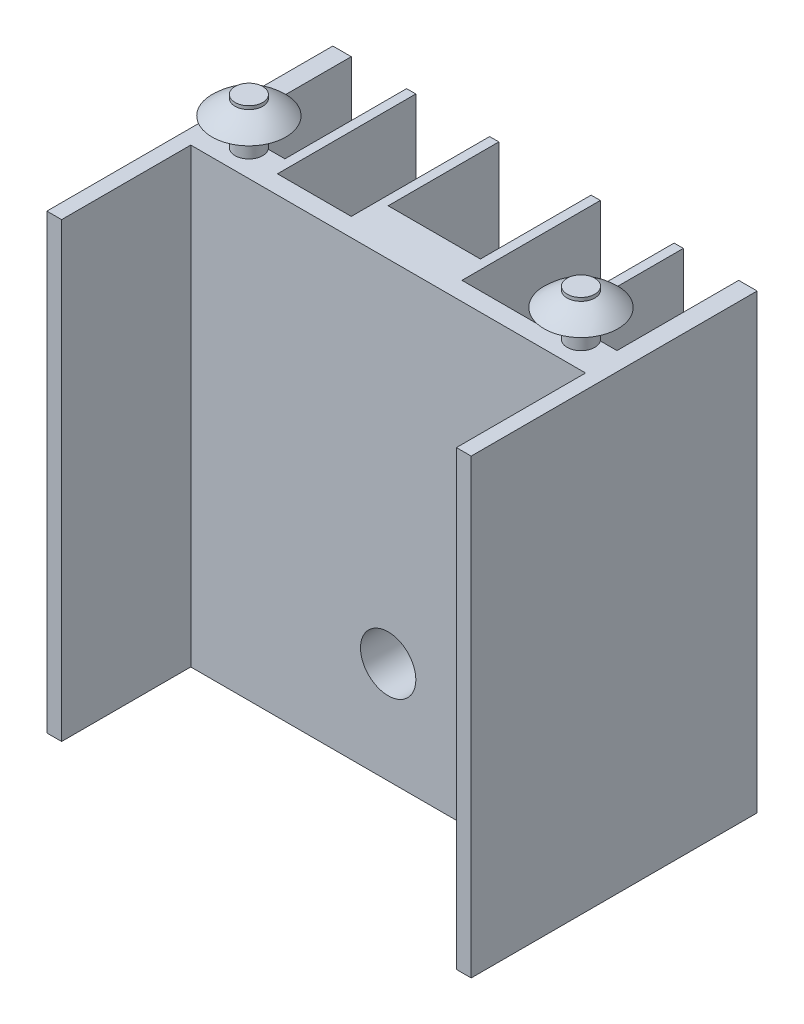
from build123d import *

# Parameters (mm, degrees)
IZIM1_W                          = 23
IZIM1_H                          = 15.5
Y_KSEKLIK_EKSTR_ZYON1_DEPTH      = 24.5
IZIM2_W                          = 21.4
IZIM2_H                          = 7
IZIM2_W_2                        = 5
IZIM2_H_2                        = 6
IZIM2_W_3                        = 4
IZIM2_H_3                        = 7.5
KES_EKSTR_ZYON1_DEPTH            = 24.5
IZIM3_R                          = 0.75
Y_KSEKLIK_EKSTR_ZYON4_DEPTH      = 2.5
Y_KSEKLIK_EKSTR_ZYON4_DEPTH_BACK = 10
IZIM8_R                          = 1.5
KES_EKSTR_ZYON3_DEPTH            = 10


with BuildPart() as part:
    # Çizim1 → Yükseklik-Ekstrüzyon1 (new body)
    with BuildSketch(Plane(origin=(0, 0, 0), x_dir=(1, 0, 0), z_dir=(0, 1, 0))):
        Rectangle(IZIM1_W, IZIM1_H)
    extrude(amount=Y_KSEKLIK_EKSTR_ZYON1_DEPTH)

    # Çizim2 → Kes-Ekstrüzyon1 (cut)
    with BuildSketch(Plane(origin=(0, 0, 0), x_dir=(1, 0, 0), z_dir=(0, 1, 0))):
        with Locations((0, -4.25)):
            Rectangle(IZIM2_W, IZIM2_H)
        Polygon((-8.5, 1.153663729), (-7.5, 1.153663729), (-7.5, 7.75), (-10.5, 7.75), (-10.5, 1.153663729), (-9.5, 1.153663729), (-9.5, 0.25), (-8.5, 0.25), align=None)
        with Locations((0, 4.75)):
            Rectangle(IZIM2_W_2, IZIM2_H_2)
        with Locations((-5, 4)):
            Rectangle(IZIM2_W_3, IZIM2_H_3)
        with Locations((5, 4)):
            Rectangle(IZIM2_W_3, IZIM2_H_3)
        Polygon((10.5, 7.75), (7.5, 7.75), (7.5, 1.153663729), (8.5, 1.153663729), (8.5, 0.25), (9.5, 0.25), (9.5, 1.153663729), (10.5, 1.153663729), align=None)
    extrude(amount=KES_EKSTR_ZYON1_DEPTH, mode=Mode.SUBTRACT)

    # Çizim3 → Yükseklik-Ekstrüzyon4 (add, two sides)
    with BuildSketch(Plane(origin=(0, 24.5, 0), x_dir=(1, 0, 0), z_dir=(0, 1, 0))) as y_kseklik_ekstr_zyon4_sk:
        with Locations((-9, 0.701831864)):
            Circle(IZIM3_R)
        with Locations((9, 0.701831864)):
            Circle(IZIM3_R)
    extrude(amount=Y_KSEKLIK_EKSTR_ZYON4_DEPTH)
    extrude(y_kseklik_ekstr_zyon4_sk.sketch, amount=-Y_KSEKLIK_EKSTR_ZYON4_DEPTH_BACK)

    # Çizim5 → Döndür2 (revolve)
    with BuildSketch(Plane.ZY.offset(9)):
        with BuildLine():
            Line((-2.701831864, 26), (-0.701831864, 26))
            Line((-0.701831864, 26), (-0.701831864, 27))
            add(Edge.make_bspline(
                [(-2.701831864, 26), (-1.790219679, 26.874416791), (-0.701831864, 27)],
                knots=[0, 0, 0, 0.748833581, 0.748833581, 0.748833581], degree=2))
        make_face()
    revolve(axis=Axis((-9, 26, -0.701831864), (0, 1, 0)))

    # Çizim6 → Döndür3 (revolve)
    with BuildSketch(Plane(origin=(9, 0, 0), x_dir=(0, 0, -1), z_dir=(1, 0, 0))):
        with BuildLine():
            Line((-1.298168136, 26), (0.701831864, 26.01043139))
            Line((0.701831864, 26.01043139), (0.701831864, 27))
            add(Edge.make_bspline(
                [(-1.298168136, 26), (-0.38655595, 26.874416791), (0.701831864, 27)],
                knots=[0, 0, 0, 0.748833581, 0.748833581, 0.748833581], degree=2))
        make_face()
    revolve(axis=Axis((9, 26.01043139, -0.701831864), (0, 1, 0)))

    # Çizim8 → Kes-Ekstrüzyon3 (cut)
    with BuildSketch(Plane.XY.offset(0.75)):
        with Locations((0, 5.5)):
            Circle(IZIM8_R)
    extrude(amount=-KES_EKSTR_ZYON3_DEPTH, mode=Mode.SUBTRACT)


solid = part.part
